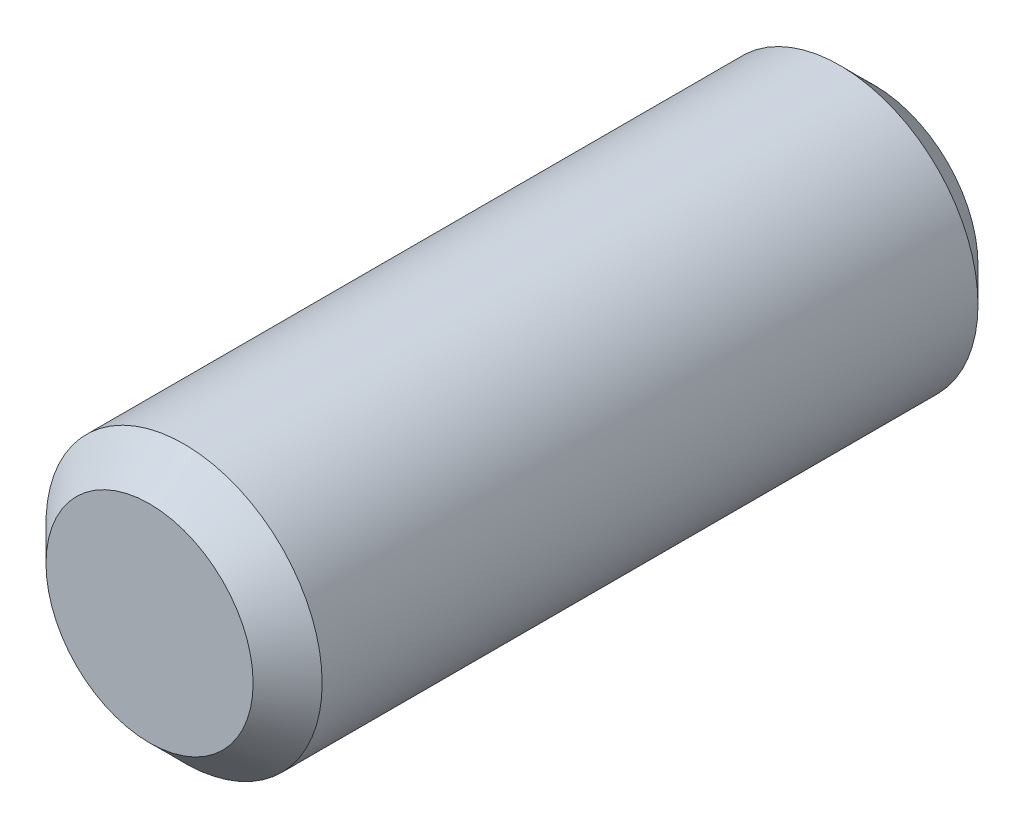
from build123d import *

# Parameters (mm, degrees)
SKETCH1_R           = 4
BOSS_EXTRUDE1_DEPTH = 21
CHAMFER1_SIZE       = 1


with BuildPart() as part:
    # Sketch1 → Boss-Extrude1 (new body)
    with BuildSketch(Plane.XY):
        Circle(SKETCH1_R)
    extrude(amount=BOSS_EXTRUDE1_DEPTH)

    # Chamfer1
    chamfer1_edges = [part.edges().sort_by_distance(p)[0] for p in [
        (-4, 0, 0),
        (-4, 0, 21),
    ]]
    chamfer(chamfer1_edges, length=CHAMFER1_SIZE)


solid = part.part
